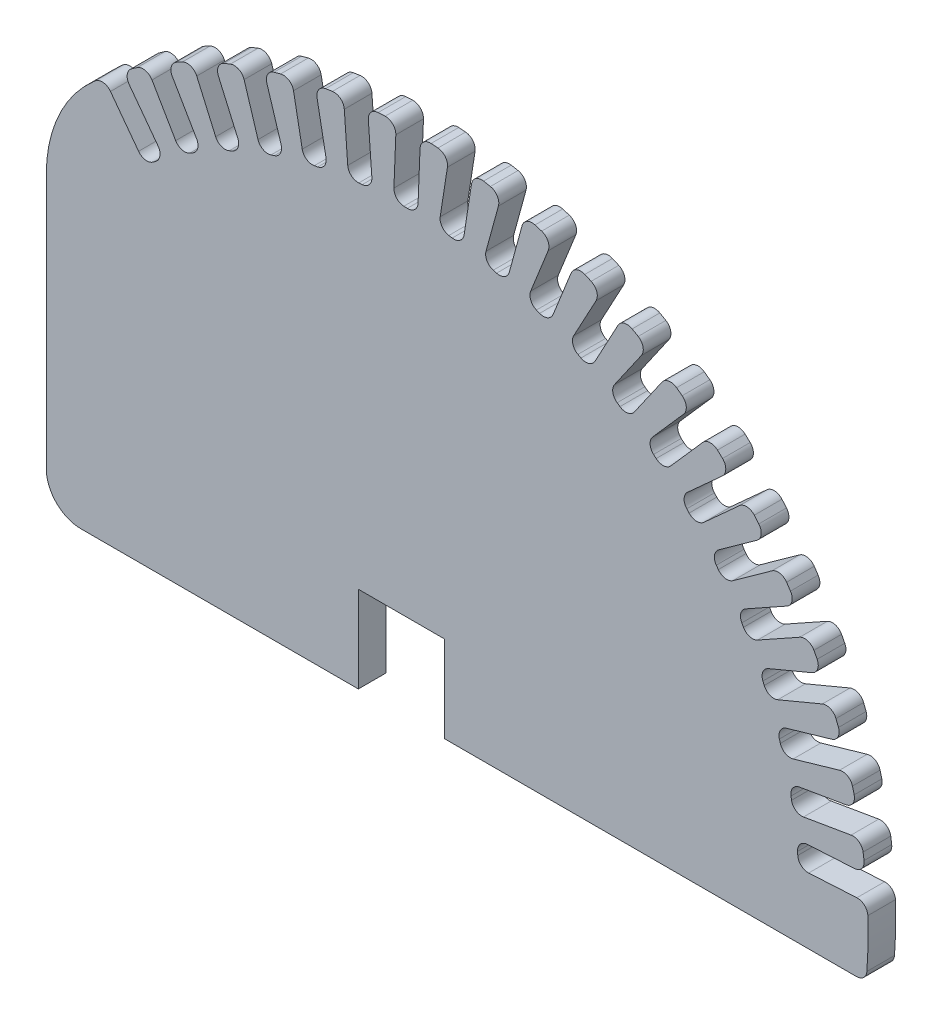
from build123d import *

# Parameters (mm, degrees)
BOSS_EXTRU_1_DEPTH                 = 8
ESQUISSE2_W                        = 32.195574025
ESQUISSE2_H                        = 100
ENL_V_MAT_EXTRU_1_DEPTH            = 9
ENL_V_MAT_EXTRU_2_DEPTH            = 9
CONG_1_R                           = 3
R_P_TITION_CIRCULAIRE1_COUNT       = 20
R_P_TITION_CIRCULAIRE1_ANGLE       = 123.5
CONG_1_OF_R_P_TITION_CIRCULAIRE1_R = 3
CONG_2_R                           = 40
CONG_3_R                           = 10
CONG_5_R                           = 3


with BuildPart() as part:
    # Esquisse1 → Boss.-Extru.1 (new body)
    with BuildSketch(Plane.XY):
        with BuildLine():
            Line((-12.5, 12.5), (0, 12.5))
            Line((0, 12.5), (12.5, 12.5))
            Line((12.5, 12.5), (12.5, 0))
            Line((12.5, 0), (12.5, -12.5))
            Line((12.5, -12.5), (134.420050588, -12.5))
            ThreePointArc((134.420050588, -12.5), (0, 135), (-134.420050588, -12.5))
            Line((-134.420050588, -12.5), (-12.5, -12.5))
            Line((-12.5, -12.5), (-12.5, 0))
            Line((-12.5, 0), (-12.5, 12.5))
        make_face()
    extrude(amount=BOSS_EXTRU_1_DEPTH)

    # Esquisse2 → Enlèv. mat.-Extru.1 (cut, through all)
    with BuildSketch(Plane.XY.offset(8)):
        with Locations((-118.902212988, 37.5)):
            Rectangle(ESQUISSE2_W, ESQUISSE2_H)
    extrude(amount=-ENL_V_MAT_EXTRU_1_DEPTH, mode=Mode.SUBTRACT)

    # Esquisse3 → Enlèv. mat.-Extru.2 (cut, through all)
    with BuildSketch(Plane.XY.offset(8)):
        with BuildLine():
            Line((-80.635390388, 108.272497971), (-68.689406627, 92.232127901))
            Line((-68.689406627, 92.232127901), (-74.303536152, 88.051033585))
            Line((-74.303536152, 88.051033585), (-86.141048213, 103.945754184))
            ThreePointArc((-86.141048213, 103.945754184), (-83.416277165, 106.144828908), (-80.635390388, 108.272497971))
        make_face()
    enl_v_mat_extru_2 = extrude(amount=-ENL_V_MAT_EXTRU_2_DEPTH, mode=Mode.SUBTRACT)

    # Congé1
    cong_1_edges = [part.edges().sort_by_distance(p)[0] for p in [
        (-86.141048213, 103.945754184, 4),
        (-80.635390388, 108.272497971, 4),
        (-68.689406627, 92.232127901, 4),
        (-74.303536152, 88.051033585, 4),
    ]]
    fillet(cong_1_edges, radius=CONG_1_R)

    # Répétition circulaire1: Enlèv. mat.-Extru.2 ×20 about axis
    r_p_tition_circulaire1_axis = Axis((0, 0, 0), (0, 0, -1))
    for i in range(1, R_P_TITION_CIRCULAIRE1_COUNT):
        add(enl_v_mat_extru_2.rotate(r_p_tition_circulaire1_axis, i * R_P_TITION_CIRCULAIRE1_ANGLE / (R_P_TITION_CIRCULAIRE1_COUNT - 1)), mode=Mode.SUBTRACT)

    # Congé1 of Répétition circulaire1
    cong_1_of_r_p_tition_circulaire1_edges = [part.edges().sort_by_distance(p)[0] for p in [
        (-73.820327691, 113.029019369, 4),
        (-67.860259728, 116.704692063, 4),
        (-57.806887917, 99.415108054, 4),
        (-63.85824232, 95.89642792, 4),
        (-60.550551729, 120.659150856, 4),
        (-54.212697982, 123.636496948, 4),
        (-46.18118717, 105.319978882, 4),
        (-52.591968493, 102.508950097, 4),
        (-46.502320397, 126.738053471, 4),
        (-39.868162141, 128.97879534, 4),
        (-33.96176775, 109.87082566, 4),
        (-40.649557138, 107.803587623, 4),
        (-31.85624181, 131.187575089, 4),
        (-25.011069701, 132.662905111, 4),
        (-21.305726041, 113.009141391, 4),
        (-28.184543343, 111.71227111, 4),
        (-16.800610184, 133.950511374, 4),
        (-9.832427729, 134.64146228, 4),
        (-8.375771769, 114.694578979, 4),
        (-15.357180924, 114.184749394, 4),
        (-1.528985063, 134.991341221, 4),
        (5.472622772, 134.889029947, 4),
        (4.661863843, 114.905469955, 4),
        (-2.332382154, 115.18923558, 4),
        (13.762297131, 134.29668342, 4),
        (20.707315655, 133.402425309, 4),
        (17.639565188, 113.639103041, 4),
        (10.722402394, 114.712815705, 4),
        (28.87664726, 131.875468693, 4),
        (35.675789311, 130.200760585, 4),
        (30.390487191, 110.911759017, 4),
        (23.639336642, 112.761614759, 4),
        (43.619750877, 127.758824875, 4),
        (50.185604722, 125.325197302, 4),
        (42.750700319, 106.758501405, 4),
        (36.252356755, 109.360717946, 4),
        (57.802066386, 121.999676727, 4),
        (64.050219512, 118.838417107, 4),
        (54.561298103, 101.232725683, 4),
        (48.399306105, 104.553848177, 4),
        (71.241261845, 114.67206552, 4),
        (77.091386193, 110.823815919, 4),
        (65.67044009, 94.40547282, 4),
        (59.924020006, 98.402803956, 4),
        (83.764559079, 105.87019714, 4),
        (89.14144376, 101.384431765, 4),
        (75.935303944, 86.364515948, 4),
        (70.678333408, 90.986664884, 4),
        (95.210954962, 95.707230945, 4),
        (100.045473197, 90.641620092, 4),
        (85.223921612, 77.21323193, 4),
        (80.523985755, 82.400774985, 4),
        (105.433291326, 84.313824964, 4),
        (109.663289152, 78.733493587, 4),
        (93.416875944, 67.069272315, 4),
        (89.334398499, 72.755516938, 4),
        (114.300146864, 71.836456113, 4),
        (117.871242207, 65.813146563, 4),
        (100.408835954, 56.063050776, 4),
        (96.996302429, 62.174892965, 4),
        (121.697526722, 58.435537046, 4),
        (124.56380855, 52.04668673, 4),
        (106.109910987, 44.336066474, 4),
        (103.411193897, 50.794930621, 4),
        (127.530328048, 44.283353848, 4),
        (129.654946615, 37.611099669, 4),
        (110.446806376, 32.039084903, 4),
        (108.496601208, 38.761933987, 4),
        (131.723562666, 29.56185107, 4),
        (133.079203262, 22.691973455, 4),
        (113.363765741, 19.33019961, 4),
        (112.187144896, 26.230602742, 4),
        (134.22332114, 14.460292602, 4),
        (134.792555258, 7.481112679, 4),
        (114.823287813, 6.37279969, 4),
        (114.435378266, 13.362043296, 4),
    ]]
    fillet(cong_1_of_r_p_tition_circulaire1_edges, radius=CONG_1_OF_R_P_TITION_CIRCULAIRE1_R)

    # Congé2
    cong_2_edges = [part.edges().sort_by_distance(p)[0] for p in [
        (-102.804425975, 87.5, 4),
    ]]
    fillet(cong_2_edges, radius=CONG_2_R)

    # Congé3
    cong_3_edges = [part.edges().sort_by_distance(p)[0] for p in [
        (-102.804425975, -12.5, 4),
    ]]
    fillet(cong_3_edges, radius=CONG_3_R)

    # Congé5
    cong_5_edges = [part.edges().sort_by_distance(p)[0] for p in [
        (134.420050588, -12.5, 4),
    ]]
    fillet(cong_5_edges, radius=CONG_5_R)


solid = part.part
